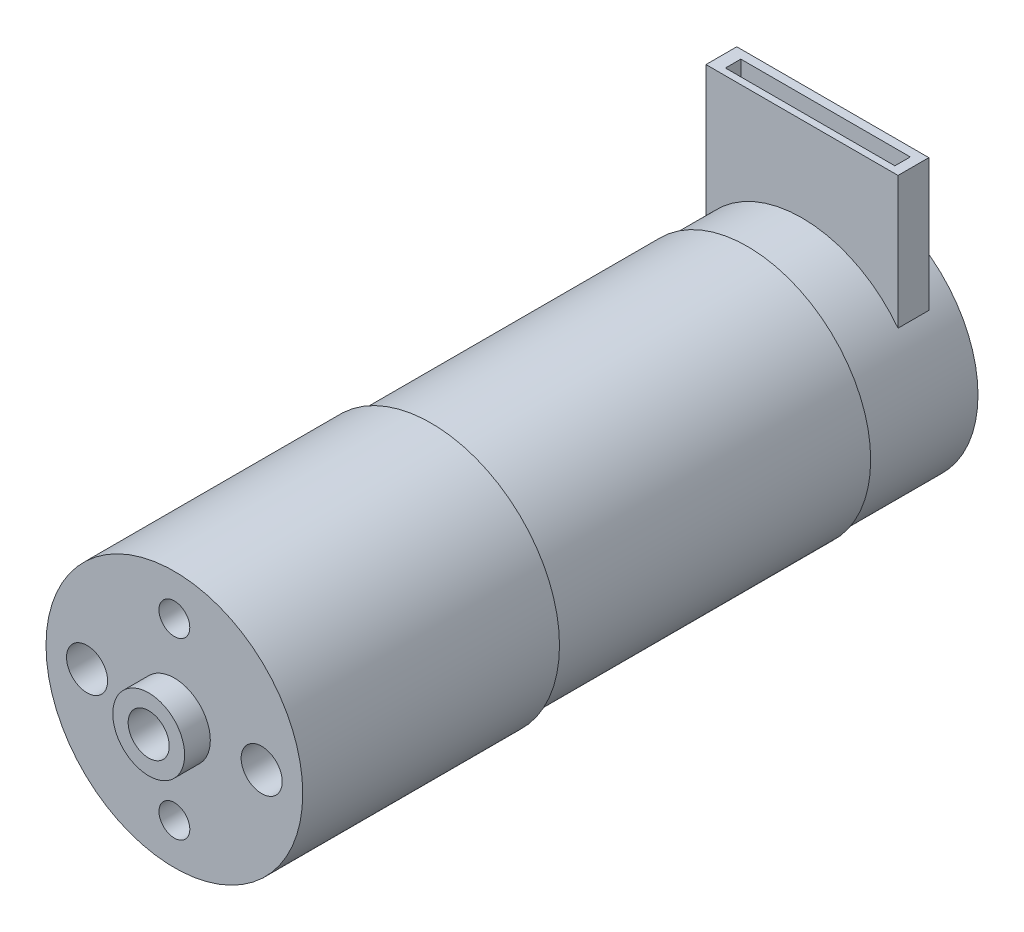
from build123d import *

# Parameters (mm, degrees)
SKETCH1_R           = 12
BOSS_EXTRUDE1_DEPTH = 30.8
SKETCH2_R           = 12.5
BOSS_EXTRUDE2_DEPTH = 25
SKETCH3_R           = 3.5
BOSS_EXTRUDE3_DEPTH = 2.5
SKETCH6_R           = 11.75
BOSS_EXTRUDE5_DEPTH = 10.7
SKETCH7_W           = 18.699432978
SKETCH7_H           = 3
BOSS_EXTRUDE6_DEPTH = 20
SKETCH10_W          = 16.5
SKETCH10_H          = 1.5
CUT_EXTRUDE4_DEPTH  = 10
SKETCH4_R           = 2
CUT_EXTRUDE7_DEPTH  = 10
SKETCH11_R          = 1.5
SKETCH11_R_2        = 2
CUT_EXTRUDE8_DEPTH  = 10


with BuildPart() as part:
    # Sketch1 → Boss-Extrude1 (new body)
    with BuildSketch(Plane.XY):
        Circle(SKETCH1_R)
    extrude(amount=BOSS_EXTRUDE1_DEPTH)

    # Sketch2 → Boss-Extrude2 (add)
    with BuildSketch(Plane.XY.offset(30.8)):
        Circle(SKETCH2_R)
    extrude(amount=BOSS_EXTRUDE2_DEPTH)

    # Sketch3 → Boss-Extrude3 (add)
    with BuildSketch(Plane.XY.offset(55.8)):
        Circle(SKETCH3_R)
    extrude(amount=BOSS_EXTRUDE3_DEPTH)

    # Sketch6 → Boss-Extrude5 (add)
    with BuildSketch(Plane(origin=(0, 0, 0), x_dir=(-1, 0, 0), z_dir=(0, 0, -1))):
        Circle(SKETCH6_R)
    extrude(amount=BOSS_EXTRUDE5_DEPTH)

    # Sketch7 → Boss-Extrude6 (add)
    with BuildSketch(Plane(origin=(0, 0, 0), x_dir=(1, 0, 0), z_dir=(0, 1, 0))):
        with Locations((0, 6.81237414)):
            Rectangle(SKETCH7_W, SKETCH7_H)
    extrude(amount=BOSS_EXTRUDE6_DEPTH)

    # Sketch10 → Cut-Extrude4 (cut)
    with BuildSketch(Plane(origin=(0, 20, 0), x_dir=(1, 0, 0), z_dir=(0, 1, 0))):
        with Locations((0.137296408, 6.718389465)):
            Rectangle(SKETCH10_W, SKETCH10_H)
    extrude(amount=-CUT_EXTRUDE4_DEPTH, mode=Mode.SUBTRACT)

    # Sketch4 → Cut-Extrude7 (cut)
    with BuildSketch(Plane.XY.offset(58.3)):
        Circle(SKETCH4_R)
    extrude(amount=-CUT_EXTRUDE7_DEPTH, mode=Mode.SUBTRACT)

    # Sketch11 → Cut-Extrude8 (cut)
    with BuildSketch(Plane.XY.offset(55.8)):
        with Locations((0, 8.5)):
            Circle(SKETCH11_R)
        with Locations((8.5, 0)):
            Circle(SKETCH11_R_2)
        with Locations((-8.5, 0)):
            Circle(SKETCH11_R_2)
        with Locations((0, -8.5)):
            Circle(SKETCH11_R)
    extrude(amount=-CUT_EXTRUDE8_DEPTH, mode=Mode.SUBTRACT)


solid = part.part
